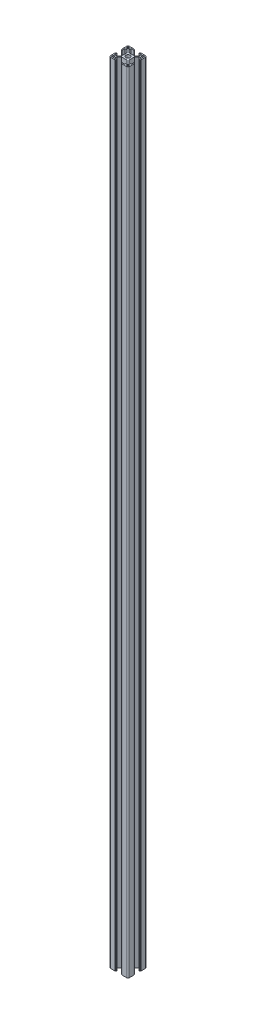
from build123d import *

# Parameters (mm, degrees)
SKETCH_3_R      = 3.4
EXTRUDE_1_DEPTH = 1248.8


with BuildPart() as part:
    # 草图3 → 凸台-拉伸1 (new body)
    with BuildSketch(Plane(origin=(0, 0, 0), x_dir=(1, 0, 0), z_dir=(0, 1, 0))):
        with BuildLine():
            Line((-15, -12.5), (-15, -5.4))
            ThreePointArc((-15, -5.4), (-14.941421356, -5.258578644), (-14.8, -5.2))
            Line((-14.8, -5.2), (-14.4, -5.2))
            ThreePointArc((-14.4, -5.2), (-14.258578644, -5.141421356), (-14.2, -5))
            Line((-14.2, -5), (-14.2, -4.3))
            ThreePointArc((-14.2, -4.3), (-14.141421356, -4.158578644), (-14, -4.1))
            Line((-14, -4.1), (-13.2, -4.1))
            Line((-13.2, -4.1), (-13.2, -8.25))
            Line((-13.2, -8.25), (-9.522792206, -8.25))
            Line((-9.522792206, -8.25), (-5.8, -4.527207794))
            Line((-5.8, -4.527207794), (-5.8, 4.527207794))
            Line((-5.8, 4.527207794), (-9.522792206, 8.25))
            Line((-9.522792206, 8.25), (-13.2, 8.25))
            Line((-13.2, 8.25), (-13.2, 4.1))
            Line((-13.2, 4.1), (-14, 4.1))
            ThreePointArc((-14, 4.1), (-14.141421356, 4.158578644), (-14.2, 4.3))
            Line((-14.2, 4.3), (-14.2, 5))
            ThreePointArc((-14.2, 5), (-14.258578644, 5.141421356), (-14.4, 5.2))
            Line((-14.4, 5.2), (-14.8, 5.2))
            ThreePointArc((-14.8, 5.2), (-14.941421356, 5.258578644), (-15, 5.4))
            Line((-15, 5.4), (-15, 12.5))
            ThreePointArc((-15, 12.5), (-14.267766953, 14.267766953), (-12.5, 15))
            Line((-12.5, 15), (-5.4, 15))
            ThreePointArc((-5.4, 15), (-5.258578644, 14.941421356), (-5.2, 14.8))
            Line((-5.2, 14.8), (-5.2, 14.4))
            ThreePointArc((-5.2, 14.4), (-5.141421356, 14.258578644), (-5, 14.2))
            Line((-5, 14.2), (-4.3, 14.2))
            ThreePointArc((-4.3, 14.2), (-4.158578644, 14.141421356), (-4.1, 14))
            Line((-4.1, 14), (-4.1, 13.2))
            Line((-4.1, 13.2), (-8.25, 13.2))
            Line((-8.25, 13.2), (-8.25, 9.522792206))
            Line((-8.25, 9.522792206), (-4.527207794, 5.8))
            Line((-4.527207794, 5.8), (4.527207794, 5.8))
            Line((4.527207794, 5.8), (8.25, 9.522792206))
            Line((8.25, 9.522792206), (8.25, 13.2))
            Line((8.25, 13.2), (4.1, 13.2))
            Line((4.1, 13.2), (4.1, 14))
            ThreePointArc((4.1, 14), (4.158578644, 14.141421356), (4.3, 14.2))
            Line((4.3, 14.2), (5, 14.2))
            ThreePointArc((5, 14.2), (5.141421356, 14.258578644), (5.2, 14.4))
            Line((5.2, 14.4), (5.2, 14.8))
            ThreePointArc((5.2, 14.8), (5.258578644, 14.941421356), (5.4, 15))
            Line((5.4, 15), (12.5, 15))
            ThreePointArc((12.5, 15), (14.267766953, 14.267766953), (15, 12.5))
            Line((15, 12.5), (15, 5.4))
            ThreePointArc((15, 5.4), (14.941421356, 5.258578644), (14.8, 5.2))
            Line((14.8, 5.2), (14.4, 5.2))
            ThreePointArc((14.4, 5.2), (14.258578644, 5.141421356), (14.2, 5))
            Line((14.2, 5), (14.2, 4.3))
            ThreePointArc((14.2, 4.3), (14.141421356, 4.158578644), (14, 4.1))
            Line((14, 4.1), (13.2, 4.1))
            Line((13.2, 4.1), (13.2, 8.25))
            Line((13.2, 8.25), (9.522792206, 8.25))
            Line((9.522792206, 8.25), (5.8, 4.527207794))
            Line((5.8, 4.527207794), (5.8, -4.527207794))
            Line((5.8, -4.527207794), (9.522792206, -8.25))
            Line((9.522792206, -8.25), (13.2, -8.25))
            Line((13.2, -8.25), (13.2, -4.1))
            Line((13.2, -4.1), (14, -4.1))
            ThreePointArc((14, -4.1), (14.141421356, -4.158578644), (14.2, -4.3))
            Line((14.2, -4.3), (14.2, -5))
            ThreePointArc((14.2, -5), (14.258578644, -5.141421356), (14.4, -5.2))
            Line((14.4, -5.2), (14.8, -5.2))
            ThreePointArc((14.8, -5.2), (14.941421356, -5.258578644), (15, -5.4))
            Line((15, -5.4), (15, -12.5))
            ThreePointArc((15, -12.5), (14.267766953, -14.267766953), (12.5, -15))
            Line((12.5, -15), (5.4, -15))
            ThreePointArc((5.4, -15), (5.258578644, -14.941421356), (5.2, -14.8))
            Line((5.2, -14.8), (5.2, -14.4))
            ThreePointArc((5.2, -14.4), (5.141421356, -14.258578644), (5, -14.2))
            Line((5, -14.2), (4.3, -14.2))
            ThreePointArc((4.3, -14.2), (4.158578644, -14.141421356), (4.1, -14))
            Line((4.1, -14), (4.1, -13.2))
            Line((4.1, -13.2), (8.25, -13.2))
            Line((8.25, -13.2), (8.25, -9.522792206))
            Line((8.25, -9.522792206), (4.527207794, -5.8))
            Line((4.527207794, -5.8), (-4.527207794, -5.8))
            Line((-4.527207794, -5.8), (-8.25, -9.522792206))
            Line((-8.25, -9.522792206), (-8.25, -13.2))
            Line((-8.25, -13.2), (-4.1, -13.2))
            Line((-4.1, -13.2), (-4.1, -14))
            ThreePointArc((-4.1, -14), (-4.158578644, -14.141421356), (-4.3, -14.2))
            Line((-4.3, -14.2), (-5, -14.2))
            ThreePointArc((-5, -14.2), (-5.141421356, -14.258578644), (-5.2, -14.4))
            Line((-5.2, -14.4), (-5.2, -14.8))
            ThreePointArc((-5.2, -14.8), (-5.258578644, -14.941421356), (-5.4, -15))
            Line((-5.4, -15), (-12.5, -15))
            ThreePointArc((-12.5, -15), (-14.267766953, -14.267766953), (-15, -12.5))
        make_face()
        Circle(SKETCH_3_R, mode=Mode.SUBTRACT)
        with BuildLine():
            Line((-13.2, -12.2), (-13.2, -11.05))
            ThreePointArc((-13.2, -11.05), (-12.907106781, -10.342893219), (-12.2, -10.05))
            Line((-12.2, -10.05), (-11.05, -10.05))
            ThreePointArc((-11.05, -10.05), (-10.342893219, -10.342893219), (-10.05, -11.05))
            Line((-10.05, -11.05), (-10.05, -12.2))
            ThreePointArc((-10.05, -12.2), (-10.342893219, -12.907106781), (-11.05, -13.2))
            Line((-11.05, -13.2), (-12.2, -13.2))
            ThreePointArc((-12.2, -13.2), (-12.907106781, -12.907106781), (-13.2, -12.2))
        make_face(mode=Mode.SUBTRACT)
        with BuildLine():
            Line((-10.05, 12.2), (-10.05, 11.05))
            ThreePointArc((-10.05, 11.05), (-10.342893219, 10.342893219), (-11.05, 10.05))
            Line((-11.05, 10.05), (-12.2, 10.05))
            ThreePointArc((-12.2, 10.05), (-12.907106781, 10.342893219), (-13.2, 11.05))
            Line((-13.2, 11.05), (-13.2, 12.2))
            ThreePointArc((-13.2, 12.2), (-12.907106781, 12.907106781), (-12.2, 13.2))
            Line((-12.2, 13.2), (-11.05, 13.2))
            ThreePointArc((-11.05, 13.2), (-10.342893219, 12.907106781), (-10.05, 12.2))
        make_face(mode=Mode.SUBTRACT)
        with BuildLine():
            Line((13.2, 12.2), (13.2, 11.05))
            ThreePointArc((13.2, 11.05), (12.907106781, 10.342893219), (12.2, 10.05))
            Line((12.2, 10.05), (11.05, 10.05))
            ThreePointArc((11.05, 10.05), (10.342893219, 10.342893219), (10.05, 11.05))
            Line((10.05, 11.05), (10.05, 12.2))
            ThreePointArc((10.05, 12.2), (10.342893219, 12.907106781), (11.05, 13.2))
            Line((11.05, 13.2), (12.2, 13.2))
            ThreePointArc((12.2, 13.2), (12.907106781, 12.907106781), (13.2, 12.2))
        make_face(mode=Mode.SUBTRACT)
        with BuildLine():
            Line((10.05, -12.2), (10.05, -11.05))
            ThreePointArc((10.05, -11.05), (10.342893219, -10.342893219), (11.05, -10.05))
            Line((11.05, -10.05), (12.2, -10.05))
            ThreePointArc((12.2, -10.05), (12.907106781, -10.342893219), (13.2, -11.05))
            Line((13.2, -11.05), (13.2, -12.2))
            ThreePointArc((13.2, -12.2), (12.907106781, -12.907106781), (12.2, -13.2))
            Line((12.2, -13.2), (11.05, -13.2))
            ThreePointArc((11.05, -13.2), (10.342893219, -12.907106781), (10.05, -12.2))
        make_face(mode=Mode.SUBTRACT)
    extrude(amount=EXTRUDE_1_DEPTH)


solid = part.part
